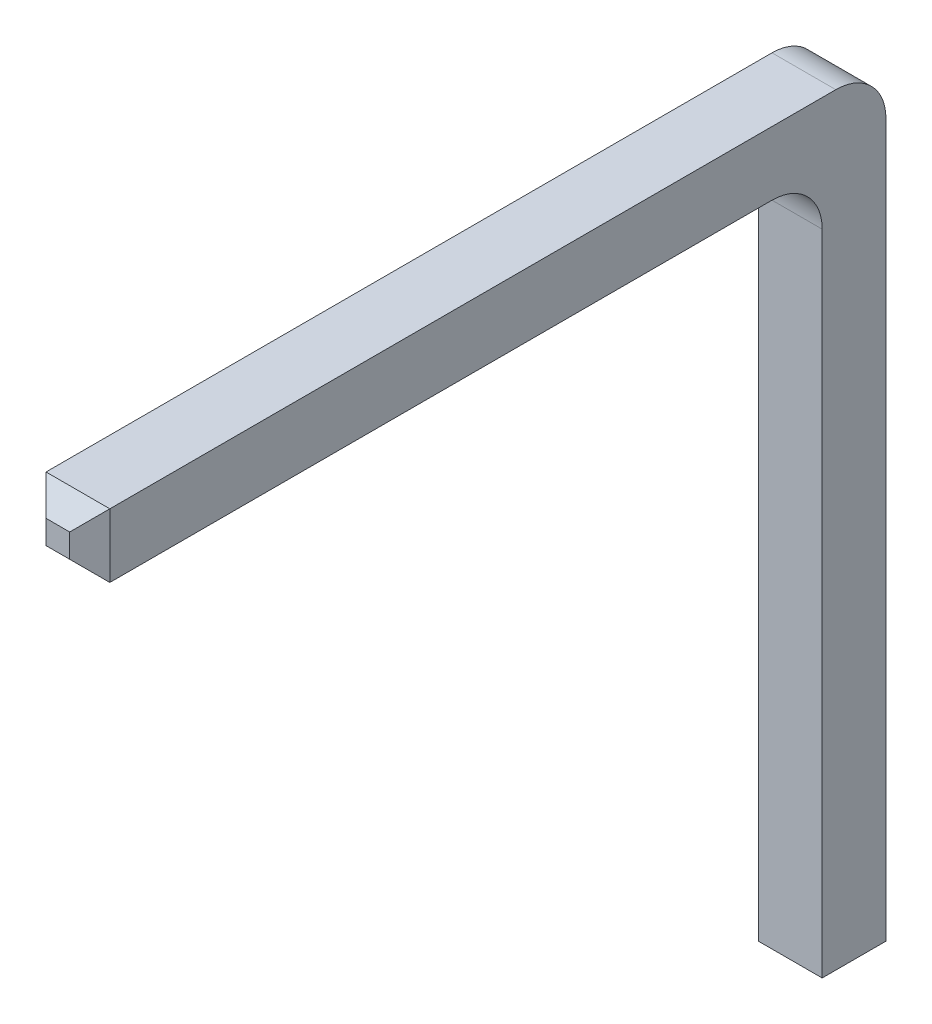
from build123d import *

# Parameters (mm, degrees)
CROQUIS1_W              = 0.636
CROQUIS1_H              = 0.636
SALIENTE_EXTRUIR1_DEPTH = 7.8
CROQUIS2_W              = 0.636
CROQUIS2_H              = 0.636
SALIENTE_EXTRUIR2_DEPTH = 7.3
REDONDEO1_R             = 0.5
CHAFL_N1_SIZE           = 0.2
CHAFL_N2_SIZE           = 0.2


with BuildPart() as part:
    # Croquis1 → Saliente-Extruir1 (new body)
    with BuildSketch(Plane(origin=(0, 0, 0), x_dir=(1, 0, 0), z_dir=(0, 1, 0))):
        with Locations((0.318, -0.318)):
            Rectangle(CROQUIS1_W, CROQUIS1_H)
    extrude(amount=SALIENTE_EXTRUIR1_DEPTH)

    # Croquis2 → Saliente-Extruir2 (add)
    with BuildSketch(Plane.XY.offset(0.636)):
        with Locations((0.318, 7.482)):
            Rectangle(CROQUIS2_W, CROQUIS2_H)
    extrude(amount=SALIENTE_EXTRUIR2_DEPTH)

    # Redondeo1
    redondeo1_edges = [part.edges().sort_by_distance(p)[0] for p in [
        (0.318, 7.164, 0.636),
        (0.318, 7.8, 0),
    ]]
    fillet(redondeo1_edges, radius=REDONDEO1_R)

    # Chaflán1
    chafl_n1_edges = [part.edges().sort_by_distance(p)[0] for p in [
        (0.636, 7.482, 7.936),
        (0.318, 7.8, 7.936),
        (0, 7.482, 7.936),
        (0.318, 7.164, 7.936),
    ]]
    chamfer(chafl_n1_edges, length=CHAFL_N1_SIZE)

    # Chaflán2
    chafl_n2_edges = [part.edges().sort_by_distance(p)[0] for p in [
        (0.318, 0, 0),
        (0.636, 0, 0.318),
        (0.318, 0, 0.636),
        (0, 0, 0.318),
    ]]
    chamfer(chafl_n2_edges, length=CHAFL_N2_SIZE)


solid = part.part
